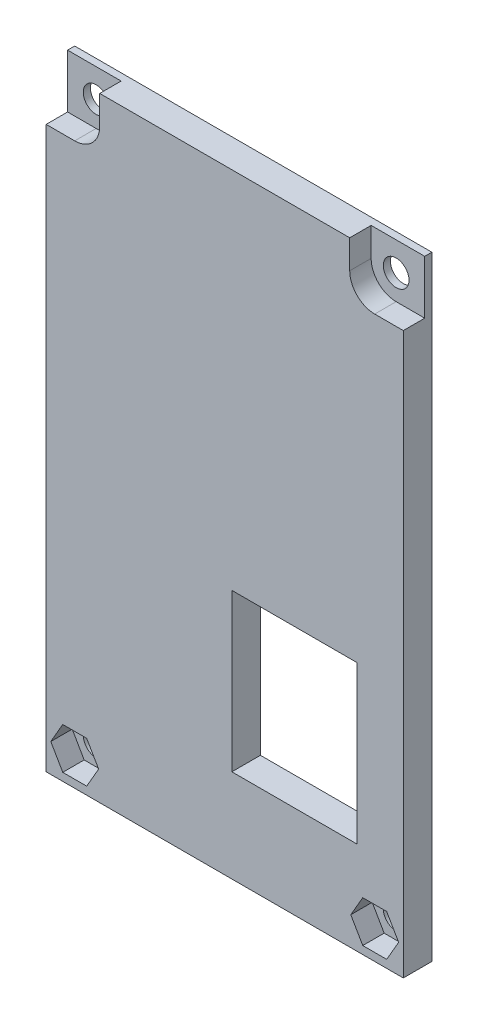
from build123d import *

# Parameters (mm, degrees)
SKETCH_1_W                  = 50
SKETCH_1_H                  = 86
EXTRUDE_1_DEPTH             = 4
SKETCH_2_W                  = 17.5
SKETCH_2_H                  = 22
CUT_EXTRUDE_1_DEPTH         = 5
CUT_EXTRUDE_2_DEPTH         = 3
SKETCH_4_W                  = 7.5
SKETCH_4_H                  = 3
CUT_EXTRUDE_3_DEPTH         = 7.5
SKETCH_5_W                  = 7.5
SKETCH_5_H                  = 3
CUT_EXTRUDE_4_DEPTH         = 7.5
CUT_EXTRUDE_5_DEPTH         = 3
HOLE_WIZARD_3_6_3_6_1_D     = 3.6
HOLE_WIZARD_3_6_3_6_1_DEPTH = 4
FILLET_1_R                  = 3.5


with BuildPart() as part:
    # 草图1 → 凸台-拉伸1 (new body)
    with BuildSketch(Plane(origin=(0, 0, 0), x_dir=(-1, 0, 0), z_dir=(0, 0, -1))):
        with Locations((-600, 300)):
            Rectangle(SKETCH_1_W, SKETCH_1_H)
    extrude(amount=-EXTRUDE_1_DEPTH)

    # 草图2 → 切除-拉伸1 (cut, through all)
    with BuildSketch(Plane.XY.offset(4)):
        with Locations((609.75, 281)):
            Rectangle(SKETCH_2_W, SKETCH_2_H)
    extrude(amount=-CUT_EXTRUDE_1_DEPTH, mode=Mode.SUBTRACT)

    # 草图3 → 切除-拉伸2 (cut)
    with BuildSketch(Plane.XY.offset(4)):
        Polygon((580.675, 258.098814897), (582.35, 261), (580.675, 263.901185103), (577.325, 263.901185103), (575.65, 261), (577.325, 258.098814897), align=None)
    extrude(amount=-CUT_EXTRUDE_2_DEPTH, mode=Mode.SUBTRACT)

    # 草图4 → 切除-拉伸3 (cut)
    with BuildSketch(Plane(origin=(0, 343, 0), x_dir=(-1, 0, 0), z_dir=(0, 1, 0))):
        with Locations((-578.75, 2.5)):
            Rectangle(SKETCH_4_W, SKETCH_4_H)
    extrude(amount=-CUT_EXTRUDE_3_DEPTH, mode=Mode.SUBTRACT)

    # 草图5 → 切除-拉伸4 (cut)
    with BuildSketch(Plane(origin=(0, 343, 0), x_dir=(-1, 0, 0), z_dir=(0, 1, 0))):
        with Locations((-621.25, 2.5)):
            Rectangle(SKETCH_5_W, SKETCH_5_H)
    extrude(amount=-CUT_EXTRUDE_4_DEPTH, mode=Mode.SUBTRACT)

    # 草图6 → 切除-拉伸5 (cut)
    with BuildSketch(Plane.XY.offset(4)):
        Polygon((624.35, 261), (622.675, 263.901185103), (619.325, 263.901185103), (617.65, 261), (619.325, 258.098814897), (622.675, 258.098814897), align=None)
    extrude(amount=-CUT_EXTRUDE_5_DEPTH, mode=Mode.SUBTRACT)

    # Ø3.6 (3.6) 直径孔1
    with Locations(Plane(origin=(0, 0, 0), x_dir=(-1, 0, 0), z_dir=(0, 0, -1))):
        with Locations((-579, 339), (-621, 339), (-579, 261), (-621, 261)):
            Hole(HOLE_WIZARD_3_6_3_6_1_D / 2, depth=HOLE_WIZARD_3_6_3_6_1_DEPTH)

    # 圆角1
    fillet_1_edges = [part.edges().sort_by_distance(p)[0] for p in [
        (582.5, 335.5, 2.5),
        (617.5, 335.5, 2.5),
    ]]
    fillet(fillet_1_edges, radius=FILLET_1_R)


solid = part.part
